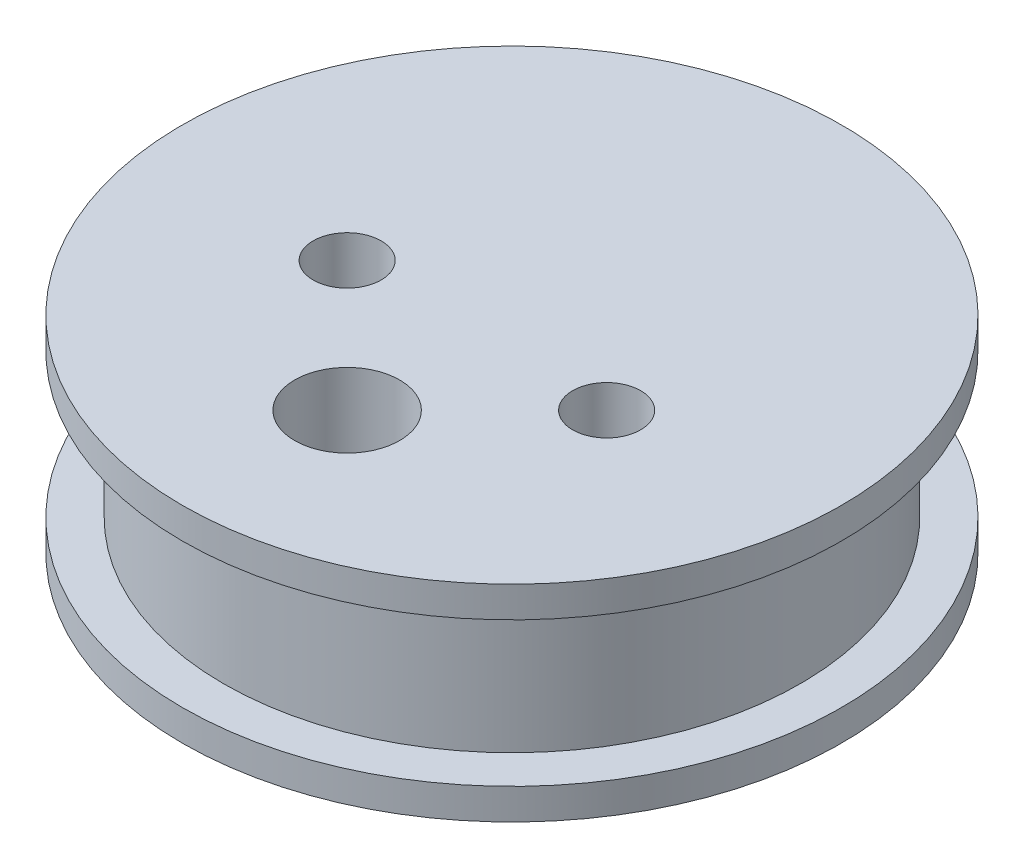
from build123d import *

# Parameters (mm, degrees)
SKETCH4_R          = 3.2385
SKETCH4_R_2        = 2.0955
CUT_EXTRUDE1_DEPTH = 13.7


with BuildPart() as part:
    # Sketch3 → Revolve1 (revolve)
    with BuildSketch(Plane.XY):
        Polygon((30.48, -1.361443582), (50.8, -1.361443582), (50.8, 0.543556418), (48.26, 0.543556418), (48.26, 9.433556418), (50.8, 9.433556418), (50.8, 11.338556418), (30.48, 11.338556418), align=None)
    revolve(axis=Axis((30.48, 11.338556418, 0), (0, -1, 0)))

    # Sketch4 → Cut-Extrude1 (cut, through all)
    with BuildSketch(Plane(origin=(0, 11.338556418, 0), x_dir=(1, 0, 0), z_dir=(0, 1, 0))):
        with Locations((30.48, -10.16)):
            Circle(SKETCH4_R)
        with Locations((22.48, -2.16)):
            Circle(SKETCH4_R_2)
        with Locations((38.48, -2.16)):
            Circle(SKETCH4_R_2)
    extrude(amount=-CUT_EXTRUDE1_DEPTH, mode=Mode.SUBTRACT)


solid = part.part
